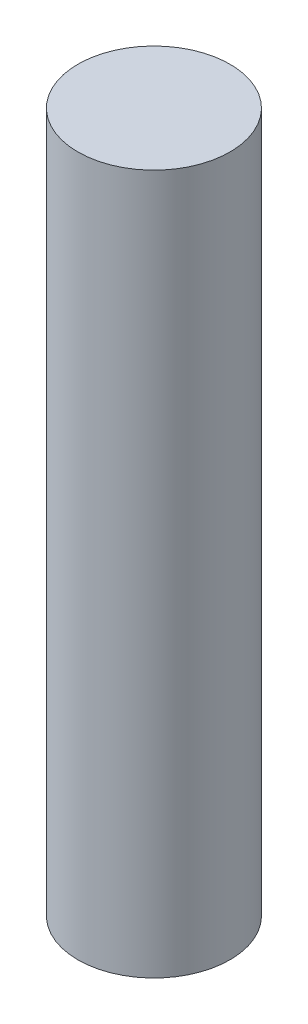
from build123d import *

# Parameters (mm, degrees)
SKETCH1_R           = 0.75
BOSS_EXTRUDE1_DEPTH = 6.9


with BuildPart() as part:
    # Sketch1 → Boss-Extrude1 (new body)
    with BuildSketch(Plane(origin=(0, 0, 0), x_dir=(1, 0, 0), z_dir=(0, 1, 0))):
        Circle(SKETCH1_R)
    extrude(amount=BOSS_EXTRUDE1_DEPTH)


solid = part.part
